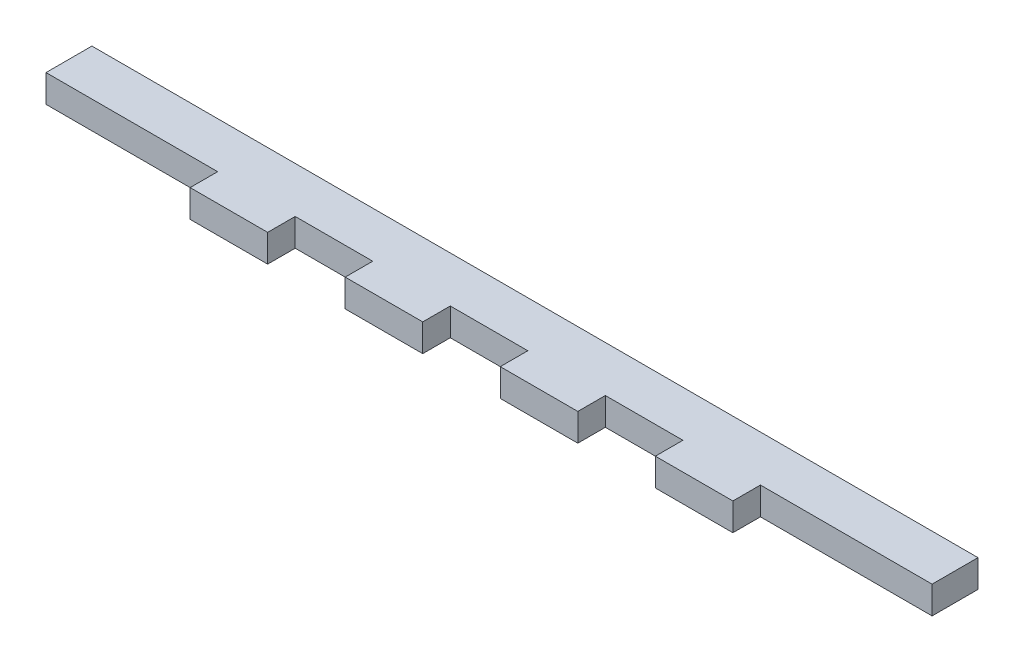
from build123d import *

# Parameters (mm, degrees)
SKETCH1_W           = 193
SKETCH1_H           = 10
BOSS_EXTRUDE1_DEPTH = 6
SKETCH4_W           = 16.888888889
SKETCH4_H           = 6
BOSS_EXTRUDE3_DEPTH = 6


with BuildPart() as part:
    # Sketch1 → Boss-Extrude1 (new body)
    with BuildSketch(Plane(origin=(0, 0, 0), x_dir=(1, 0, 0), z_dir=(0, 1, 0))):
        Rectangle(SKETCH1_W, SKETCH1_H)
    extrude(amount=BOSS_EXTRUDE1_DEPTH)

    # Sketch4 → Boss-Extrude3 (add)
    with BuildSketch(Plane.XZ):
        with Locations((-16.888888889, 8)):
            Rectangle(SKETCH4_W, SKETCH4_H)
        with Locations((-50.666666667, 8)):
            Rectangle(SKETCH4_W, SKETCH4_H)
    boss_extrude3 = extrude(amount=-BOSS_EXTRUDE3_DEPTH)

    # Mirror1: Boss-Extrude3 across plane
    add(boss_extrude3.mirror(Plane(origin=(0, 0, 0), x_dir=(0, 0, 1), z_dir=(1, 0, 0))))


solid = part.part
